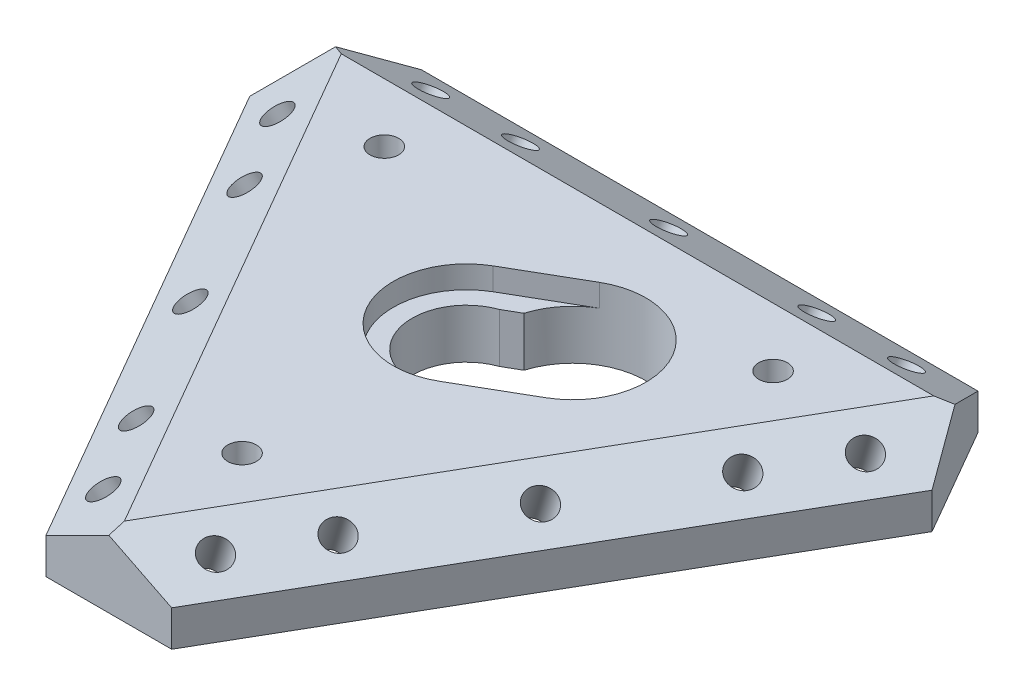
from build123d import *

# Parameters (mm, degrees)
BOSS_EXTRUDE1_DEPTH   = 8
CHAMFER1_SIZE         = 4
CHAMFER1_SIZE2        = 6.928203
CHAMFER1_PART_2_SIZE  = 4
CHAMFER1_PART_2_SIZE2 = 6.928203
CHAMFER1_PART_3_SIZE  = 4
CHAMFER1_PART_3_SIZE2 = 6.928203
CUT_EXTRUDE1_REACH    = 61.292
SKETCH2_R             = 1.6
CUT_EXTRUDE2_REACH    = 67.292
CUT_EXTRUDE2_START    = -6
SKETCH3_R             = 3
CIRPATTERN1_COUNT     = 3
CUT_EXTRUDE4_DEPTH    = 2.5
CUT_EXTRUDE5_REACH    = 57.633
SKETCH10_R            = 1.6


with BuildPart() as part:
    # Sketch1 → Boss-Extrude1 (new body)
    with BuildSketch(Plane(origin=(0, 0, 0), x_dir=(1, 0, 0), z_dir=(0, 1, 0))):
        Polygon((-31, 25.980762), (31, 25.980762), (38, 13.856406), (7, -39.837169), (-7, -39.837169), (-38, 13.856406), align=None)
        with BuildLine():
            Line((3.923683, -4.605129), (5.655734, -3.605129))
            ThreePointArc((5.655734, -3.605129), (14.562222, 8.407503), (-0.294266, 6.700574))
            Line((-0.294266, 6.700574), (-2.026317, 5.700574))
            ThreePointArc((-2.026317, 5.700574), (-5.239454, -3.025), (3.923683, -4.605129))
        make_face(mode=Mode.SUBTRACT)
    extrude(amount=BOSS_EXTRUDE1_DEPTH)

    # Chamfer1
    chamfer1_edges = [part.edges().sort_by_distance(p)[0] for p in [
        (22.5, 8, 12.990381),
    ]]
    chamfer1_side = [part.faces().sort_by_distance(p)[0] for p in [
        (22.5, 4, 12.990381),
    ]]
    chamfer(chamfer1_edges, length=CHAMFER1_SIZE, length2=CHAMFER1_SIZE2, reference=chamfer1_side[0])

    # Chamfer1 part 2
    chamfer1_part_2_edges = [part.edges().sort_by_distance(p)[0] for p in [
        (-22.5, 8, 12.990381),
    ]]
    chamfer1_part_2_side = [part.faces().sort_by_distance(p)[0] for p in [
        (-22.5, 4, 12.990381),
    ]]
    chamfer(chamfer1_part_2_edges, length=CHAMFER1_PART_2_SIZE, length2=CHAMFER1_PART_2_SIZE2, reference=chamfer1_part_2_side[0])

    # Chamfer1 part 3
    chamfer1_part_3_edges = [part.edges().sort_by_distance(p)[0] for p in [
        (0, 8, -25.980762),
    ]]
    chamfer1_part_3_side = [part.faces().sort_by_distance(p)[0] for p in [
        (0, 4, -25.980762),
    ]]
    chamfer(chamfer1_part_3_edges, length=CHAMFER1_PART_3_SIZE, length2=CHAMFER1_PART_3_SIZE2, reference=chamfer1_part_3_side[0])

    # Cut-Extrude1: up to this plane
    cut_extrude1_end = Plane(origin=(0, 0, 0), z_dir=(0, -1, 0))
    # Sketch2 → Cut-Extrude1 (cut, up to the surface)
    with BuildSketch(Plane(origin=(7.125, 14.25, 4.113621), x_dir=(0.9013878188659966, -0.41602514716892336, -0.12009611535381544), z_dir=(0.43301270189222085, 0.8660254037844383, 0.24999999999999917)), mode=Mode.PRIVATE) as cut_extrude1_sk1:
        with Locations(Location((28.428385, 12.89678, 0), (0, 0, 172.874984))):
            Circle(SKETCH2_R)
    cut_extrude1_tool1 = split(extrude(cut_extrude1_sk1.sketch, amount=-CUT_EXTRUDE1_REACH, mode=Mode.PRIVATE), bisect_by=cut_extrude1_end, keep=Keep.BOTH, mode=Mode.PRIVATE)
    # Sketch2 → Cut-Extrude1 (cut, up to the surface)
    with BuildSketch(Plane(origin=(7.125, 14.25, 4.113621), x_dir=(0.9013878188659966, -0.41602514716892336, -0.12009611535381544), z_dir=(0.43301270189222085, 0.8660254037844383, 0.24999999999999917)), mode=Mode.PRIVATE) as cut_extrude1_sk2:
        with Locations(Location((-0.970725, -31.201886, 0), (0, 0, 172.874984))):
            Circle(SKETCH2_R)
    cut_extrude1_tool2 = split(extrude(cut_extrude1_sk2.sketch, amount=-CUT_EXTRUDE1_REACH, mode=Mode.PRIVATE), bisect_by=cut_extrude1_end, keep=Keep.BOTH, mode=Mode.PRIVATE)
    # Sketch2 → Cut-Extrude1 (cut, up to the surface)
    with BuildSketch(Plane(origin=(7.125, 14.25, 4.113621), x_dir=(0.9013878188659966, -0.41602514716892336, -0.12009611535381544), z_dir=(0.43301270189222085, 0.8660254037844383, 0.24999999999999917)), mode=Mode.PRIVATE) as cut_extrude1_sk3:
        with Locations(Location((13.72883, -9.152553, 0), (0, 0, 172.874984))):
            Circle(SKETCH2_R)
    cut_extrude1_tool3 = split(extrude(cut_extrude1_sk3.sketch, amount=-CUT_EXTRUDE1_REACH, mode=Mode.PRIVATE), bisect_by=cut_extrude1_end, keep=Keep.BOTH, mode=Mode.PRIVATE)
    # Sketch2 → Cut-Extrude1 (cut, up to the surface)
    with BuildSketch(Plane(origin=(7.125, 14.25, 4.113621), x_dir=(0.9013878188659966, -0.41602514716892336, -0.12009611535381544), z_dir=(0.43301270189222085, 0.8660254037844383, 0.24999999999999917)), mode=Mode.PRIVATE) as cut_extrude1_sk4:
        with Locations(Location((22.881383, 4.576277, 0), (0, 0, 172.874984))):
            Circle(SKETCH2_R)
    cut_extrude1_tool4 = split(extrude(cut_extrude1_sk4.sketch, amount=-CUT_EXTRUDE1_REACH, mode=Mode.PRIVATE), bisect_by=cut_extrude1_end, keep=Keep.BOTH, mode=Mode.PRIVATE)
    # Sketch2 → Cut-Extrude1 (cut, up to the surface)
    with BuildSketch(Plane(origin=(7.125, 14.25, 4.113621), x_dir=(0.9013878188659966, -0.41602514716892336, -0.12009611535381544), z_dir=(0.43301270189222085, 0.8660254037844383, 0.24999999999999917)), mode=Mode.PRIVATE) as cut_extrude1_sk5:
        with Locations(Location((4.576277, -22.881383, 0), (0, 0, 172.874984))):
            Circle(SKETCH2_R)
    cut_extrude1_tool5 = split(extrude(cut_extrude1_sk5.sketch, amount=-CUT_EXTRUDE1_REACH, mode=Mode.PRIVATE), bisect_by=cut_extrude1_end, keep=Keep.BOTH, mode=Mode.PRIVATE)
    cut_extrude1 = cut_extrude1_tool1.solids().sort_by_distance((32.75, 6, -11.691343))[0] + cut_extrude1_tool2.solids().sort_by_distance((6.25, 6, 34.208003))[0] + cut_extrude1_tool3.solids().sort_by_distance((19.5, 6, 11.25833))[0] + cut_extrude1_tool4.solids().sort_by_distance((27.75, 6, -3.031089))[0] + cut_extrude1_tool5.solids().sort_by_distance((11.25, 6, 25.547749))[0]
    add(cut_extrude1, mode=Mode.SUBTRACT)

    # Sketch3 → Cut-Extrude2 (cut, up to next)
    with BuildSketch(Plane(origin=(7.125, 14.25, 4.113621), x_dir=(0.9013878188659967, -0.41602514716892325, -0.12009611535381544), z_dir=(0.43301270189222074, 0.8660254037844383, 0.24999999999999925)).offset(CUT_EXTRUDE2_START), mode=Mode.PRIVATE) as cut_extrude2_sk1:
        with Locations((28.428385, 12.89678)):
            Circle(SKETCH3_R)
    cut_extrude2_tool1 = extrude(cut_extrude2_sk1.sketch, amount=-CUT_EXTRUDE2_REACH, mode=Mode.PRIVATE) & part.part
    # Sketch3 → Cut-Extrude2 (cut, up to next)
    with BuildSketch(Plane(origin=(7.125, 14.25, 4.113621), x_dir=(0.9013878188659967, -0.41602514716892325, -0.12009611535381544), z_dir=(0.43301270189222074, 0.8660254037844383, 0.24999999999999925)).offset(CUT_EXTRUDE2_START), mode=Mode.PRIVATE) as cut_extrude2_sk2:
        with Locations((-0.970725, -31.201886)):
            Circle(SKETCH3_R)
    cut_extrude2_tool2 = extrude(cut_extrude2_sk2.sketch, amount=-CUT_EXTRUDE2_REACH, mode=Mode.PRIVATE) & part.part
    # Sketch3 → Cut-Extrude2 (cut, up to next)
    with BuildSketch(Plane(origin=(7.125, 14.25, 4.113621), x_dir=(0.9013878188659967, -0.41602514716892325, -0.12009611535381544), z_dir=(0.43301270189222074, 0.8660254037844383, 0.24999999999999925)).offset(CUT_EXTRUDE2_START), mode=Mode.PRIVATE) as cut_extrude2_sk3:
        with Locations((13.72883, -9.152553)):
            Circle(SKETCH3_R)
    cut_extrude2_tool3 = extrude(cut_extrude2_sk3.sketch, amount=-CUT_EXTRUDE2_REACH, mode=Mode.PRIVATE) & part.part
    # Sketch3 → Cut-Extrude2 (cut, up to next)
    with BuildSketch(Plane(origin=(7.125, 14.25, 4.113621), x_dir=(0.9013878188659967, -0.41602514716892325, -0.12009611535381544), z_dir=(0.43301270189222074, 0.8660254037844383, 0.24999999999999925)).offset(CUT_EXTRUDE2_START), mode=Mode.PRIVATE) as cut_extrude2_sk4:
        with Locations((22.881383, 4.576277)):
            Circle(SKETCH3_R)
    cut_extrude2_tool4 = extrude(cut_extrude2_sk4.sketch, amount=-CUT_EXTRUDE2_REACH, mode=Mode.PRIVATE) & part.part
    # Sketch3 → Cut-Extrude2 (cut, up to next)
    with BuildSketch(Plane(origin=(7.125, 14.25, 4.113621), x_dir=(0.9013878188659967, -0.41602514716892325, -0.12009611535381544), z_dir=(0.43301270189222074, 0.8660254037844383, 0.24999999999999925)).offset(CUT_EXTRUDE2_START), mode=Mode.PRIVATE) as cut_extrude2_sk5:
        with Locations((4.576277, -22.881383)):
            Circle(SKETCH3_R)
    cut_extrude2_tool5 = extrude(cut_extrude2_sk5.sketch, amount=-CUT_EXTRUDE2_REACH, mode=Mode.PRIVATE) & part.part
    cut_extrude2_1 = cut_extrude2_tool1.solids().sort_by_distance((30.151924, 0.803848, -13.191343))[0]
    add(cut_extrude2_1, mode=Mode.SUBTRACT)
    cut_extrude2_2 = cut_extrude2_tool2.solids().sort_by_distance((3.651924, 0.803848, 32.708003))[0]
    add(cut_extrude2_2, mode=Mode.SUBTRACT)
    cut_extrude2_3 = cut_extrude2_tool3.solids().sort_by_distance((16.901924, 0.803848, 9.75833))[0]
    add(cut_extrude2_3, mode=Mode.SUBTRACT)
    cut_extrude2_4 = cut_extrude2_tool4.solids().sort_by_distance((25.151924, 0.803848, -4.531089))[0]
    add(cut_extrude2_4, mode=Mode.SUBTRACT)
    cut_extrude2_5 = cut_extrude2_tool5.solids().sort_by_distance((8.651924, 0.803848, 24.047749))[0]
    add(cut_extrude2_5, mode=Mode.SUBTRACT)
    cut_extrude2 = cut_extrude2_1 + cut_extrude2_2 + cut_extrude2_3 + cut_extrude2_4 + cut_extrude2_5  # Cut-Extrude2 as one shape, for the pattern or mirror that repeats it

    # CirPattern1: Cut-Extrude1, Cut-Extrude2 ×3 about axis
    cirpattern1_axis = Axis((0, 0, 0), (0, 1, 0))
    add([cut_extrude1.rotate(cirpattern1_axis, i * 360 / CIRPATTERN1_COUNT) for i in range(1, CIRPATTERN1_COUNT)], mode=Mode.SUBTRACT)
    add([cut_extrude2.rotate(cirpattern1_axis, i * 360 / CIRPATTERN1_COUNT) for i in range(1, CIRPATTERN1_COUNT)], mode=Mode.SUBTRACT)

    # Sketch8 → Cut-Extrude4 (cut)
    with BuildSketch(Plane(origin=(0, 8, 0), x_dir=(1, 0, 0), z_dir=(0, 1, 0))):
        with BuildLine():
            Line((-4.075, 7.058107), (3.429115, 11.39061))
            ThreePointArc((3.429115, 11.39061), (14.562222, 8.407503), (11.579115, -2.725604))
            Line((11.579115, -2.725604), (4.075, -7.058107))
            ThreePointArc((4.075, -7.058107), (-7.058107, -4.075), (-4.075, 7.058107))
        make_face()
    extrude(amount=-CUT_EXTRUDE4_DEPTH, mode=Mode.SUBTRACT)

    # Sketch10 → Cut-Extrude5 (cut, up to next)
    with BuildSketch(Plane(origin=(0, 8, 0), x_dir=(1, 0, 0), z_dir=(0, 1, 0)), mode=Mode.PRIVATE) as cut_extrude5_sk1:
        with Locations(Location((21.650635, 12.5, 0), (0, 0, 270))):
            Circle(SKETCH10_R)
    cut_extrude5_tool1 = extrude(cut_extrude5_sk1.sketch, amount=-CUT_EXTRUDE5_REACH, mode=Mode.PRIVATE) & part.part
    # Sketch10 → Cut-Extrude5 (cut, up to next)
    with BuildSketch(Plane(origin=(0, 8, 0), x_dir=(1, 0, 0), z_dir=(0, 1, 0)), mode=Mode.PRIVATE) as cut_extrude5_sk2:
        with Locations(Location((0, -25, 0), (0, 0, 270))):
            Circle(SKETCH10_R)
    cut_extrude5_tool2 = extrude(cut_extrude5_sk2.sketch, amount=-CUT_EXTRUDE5_REACH, mode=Mode.PRIVATE) & part.part
    # Sketch10 → Cut-Extrude5 (cut, up to next)
    with BuildSketch(Plane(origin=(0, 8, 0), x_dir=(1, 0, 0), z_dir=(0, 1, 0)), mode=Mode.PRIVATE) as cut_extrude5_sk3:
        with Locations(Location((-21.650635, 12.5, 0), (0, 0, 270))):
            Circle(SKETCH10_R)
    cut_extrude5_tool3 = extrude(cut_extrude5_sk3.sketch, amount=-CUT_EXTRUDE5_REACH, mode=Mode.PRIVATE) & part.part
    add(cut_extrude5_tool1.solids().sort_by_distance((21.650635, 8, -12.5))[0], mode=Mode.SUBTRACT)
    add(cut_extrude5_tool2.solids().sort_by_distance((0, 8, 25))[0], mode=Mode.SUBTRACT)
    add(cut_extrude5_tool3.solids().sort_by_distance((-21.650635, 8, -12.5))[0], mode=Mode.SUBTRACT)


solid = part.part
